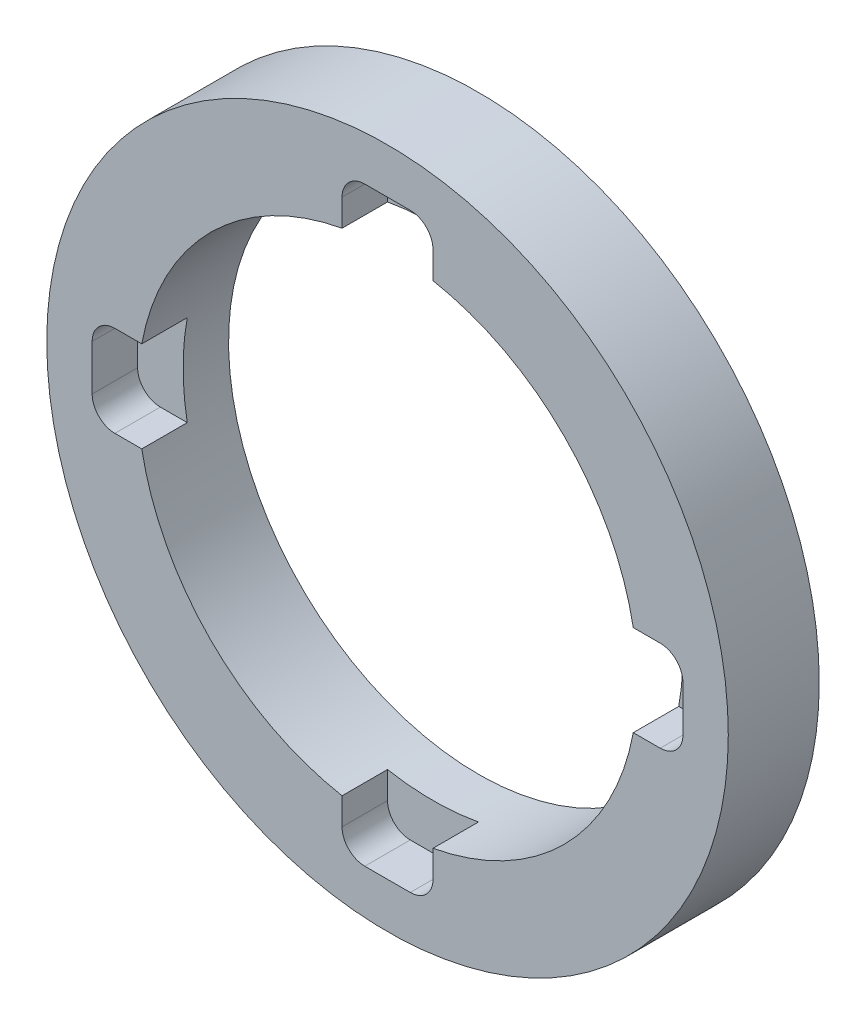
from build123d import *

# Parameters (mm, degrees)
SKETCH1_R                = 47.5869
SKETCH1_R_2              = 34.8996
BOSS_EXTRUDE1_DEPTH      = 12.7
SKETCH2_W                = 12.7
SKETCH2_H                = 82.4992
CUT_EXTRUDE1_DEPTH       = 6.35
FILLET1_R                = 3.175
CIRPATTERN1_COUNT        = 2
CIRPATTERN1_ANGLE        = 90
FILLET1_OF_CIRPATTERN1_R = 3.175


with BuildPart() as part:
    # Sketch1 → Boss-Extrude1 (new body)
    with BuildSketch(Plane.XY):
        Circle(SKETCH1_R)
        Circle(SKETCH1_R_2, mode=Mode.SUBTRACT)
    extrude(amount=BOSS_EXTRUDE1_DEPTH)

    # Sketch2 → Cut-Extrude1 (cut)
    with BuildSketch(Plane.XY.offset(12.7)):
        Rectangle(SKETCH2_W, SKETCH2_H)
    cut_extrude1 = extrude(amount=-CUT_EXTRUDE1_DEPTH, mode=Mode.SUBTRACT)

    # Fillet1
    fillet1_edges = [part.edges().sort_by_distance(p)[0] for p in [
        (6.35, 41.2496, 9.525),
        (6.35, -41.2496, 9.525),
        (-6.35, -41.2496, 9.525),
        (-6.35, 41.2496, 9.525),
    ]]
    fillet(fillet1_edges, radius=FILLET1_R)

    # CirPattern1: Cut-Extrude1 ×2 about axis
    cirpattern1_axis = Axis((0, 0, 0), (0, 0, -1))
    for i in range(1, CIRPATTERN1_COUNT):
        add(cut_extrude1.rotate(cirpattern1_axis, i * CIRPATTERN1_ANGLE / (CIRPATTERN1_COUNT - 1)), mode=Mode.SUBTRACT)

    # Fillet1 of CirPattern1
    fillet1_of_cirpattern1_edges = [part.edges().sort_by_distance(p)[0] for p in [
        (41.2496, -6.35, 9.525),
        (-41.2496, -6.35, 9.525),
        (-41.2496, 6.35, 9.525),
        (41.2496, 6.35, 9.525),
    ]]
    fillet(fillet1_of_cirpattern1_edges, radius=FILLET1_OF_CIRPATTERN1_R)


solid = part.part
